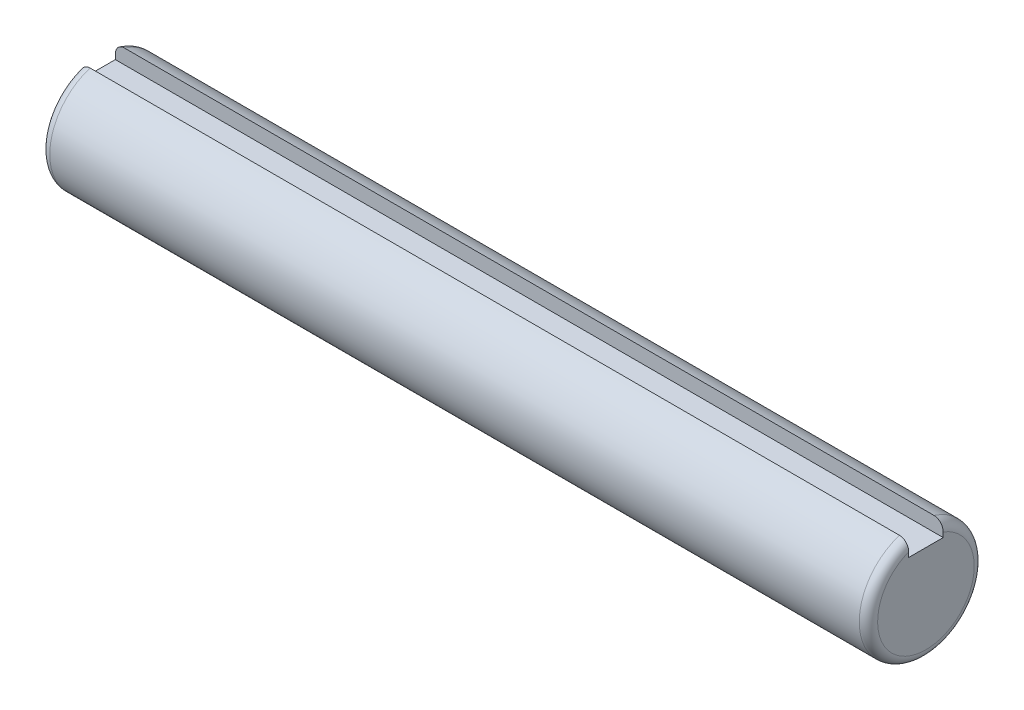
from build123d import *

# Parameters (mm, degrees)
SKETCH1_R          = 7.9375
EXTRUDE1_DEPTH     = 114.3
SKETCH2_W          = 4.7625
SKETCH2_H          = 2.38125
CUT_EXTRUDE1_DEPTH = 115.3
FILLET1_R          = 1.27


with BuildPart() as part:
    # Sketch1 → Extrude1 (new body)
    with BuildSketch(Plane(origin=(0, 0, 0), x_dir=(0, 0, -1), z_dir=(1, 0, 0))):
        Circle(SKETCH1_R)
    extrude(amount=EXTRUDE1_DEPTH)

    # Sketch2 → Cut-Extrude1 (cut, through all)
    with BuildSketch(Plane.ZY):
        with Locations((0, 6.746875)):
            Rectangle(SKETCH2_W, SKETCH2_H)
    extrude(amount=-CUT_EXTRUDE1_DEPTH, mode=Mode.SUBTRACT)

    # Fillet1
    fillet1_edges = [part.edges().sort_by_distance(p)[0] for p in [
        (0, -7.9375, 0),
        (114.3, -7.9375, 0),
    ]]
    fillet(fillet1_edges, radius=FILLET1_R)


solid = part.part
